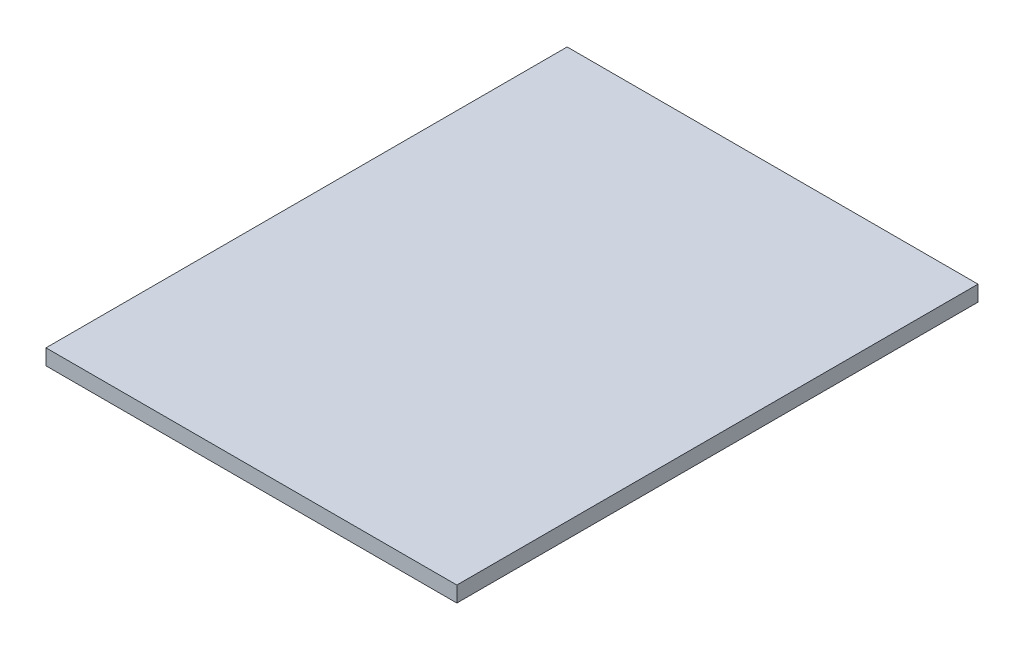
from build123d import *

# Parameters (mm, degrees)
SKETCH_1_W      = 473
SKETCH_1_H      = 600
EXTRUDE_1_DEPTH = 18


with BuildPart() as part:
    # Эскиз1 → Бобышка-Вытянуть1 (new body)
    with BuildSketch(Plane(origin=(0, 0, 0), x_dir=(1, 0, 0), z_dir=(0, 1, 0))):
        with Locations((236.5, 300)):
            Rectangle(SKETCH_1_W, SKETCH_1_H)
    extrude(amount=EXTRUDE_1_DEPTH)


solid = part.part
